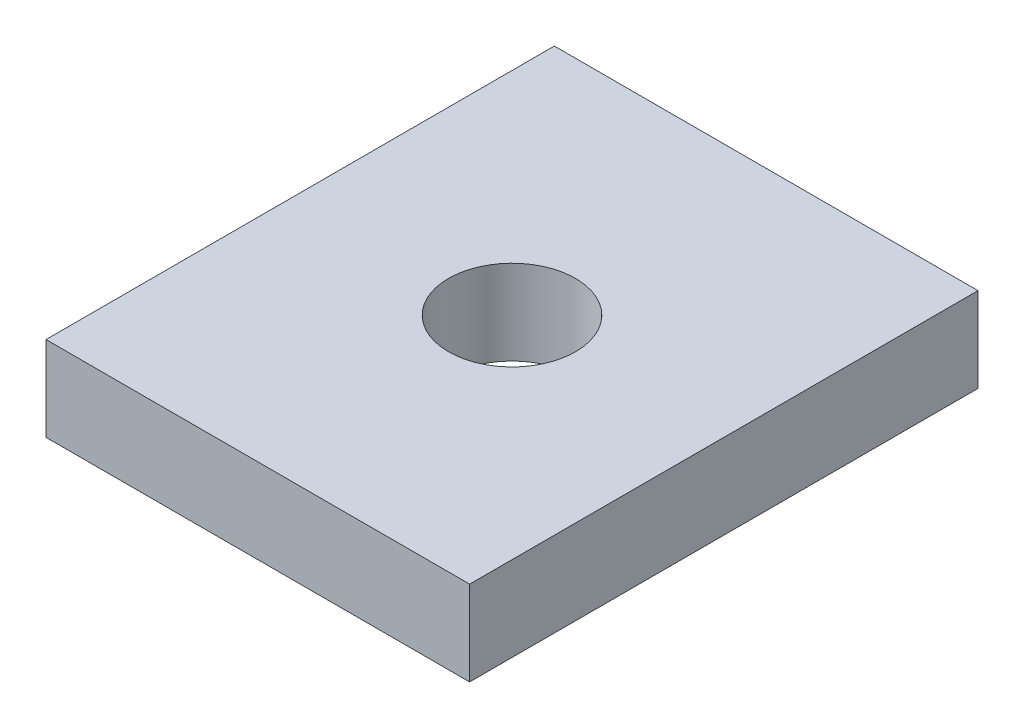
from build123d import *

# Parameters (mm, degrees)
SKETCH1_W          = 200
SKETCH1_H          = 240
BASE_DEPTH         = 40
SKETCH2_R          = 30
ACTUATOR_CUT_DEPTH = 40


with BuildPart() as part:
    # Sketch1 → base (new body)
    with BuildSketch(Plane(origin=(0, 0, 0), x_dir=(1, 0, 0), z_dir=(0, 1, 0))):
        Rectangle(SKETCH1_W, SKETCH1_H)
    extrude(amount=BASE_DEPTH)

    # Sketch2 → actuator cut (cut)
    with BuildSketch(Plane(origin=(0, 40, 0), x_dir=(1, 0, 0), z_dir=(0, 1, 0))):
        Circle(SKETCH2_R)
    extrude(amount=-ACTUATOR_CUT_DEPTH, mode=Mode.SUBTRACT)


solid = part.part
